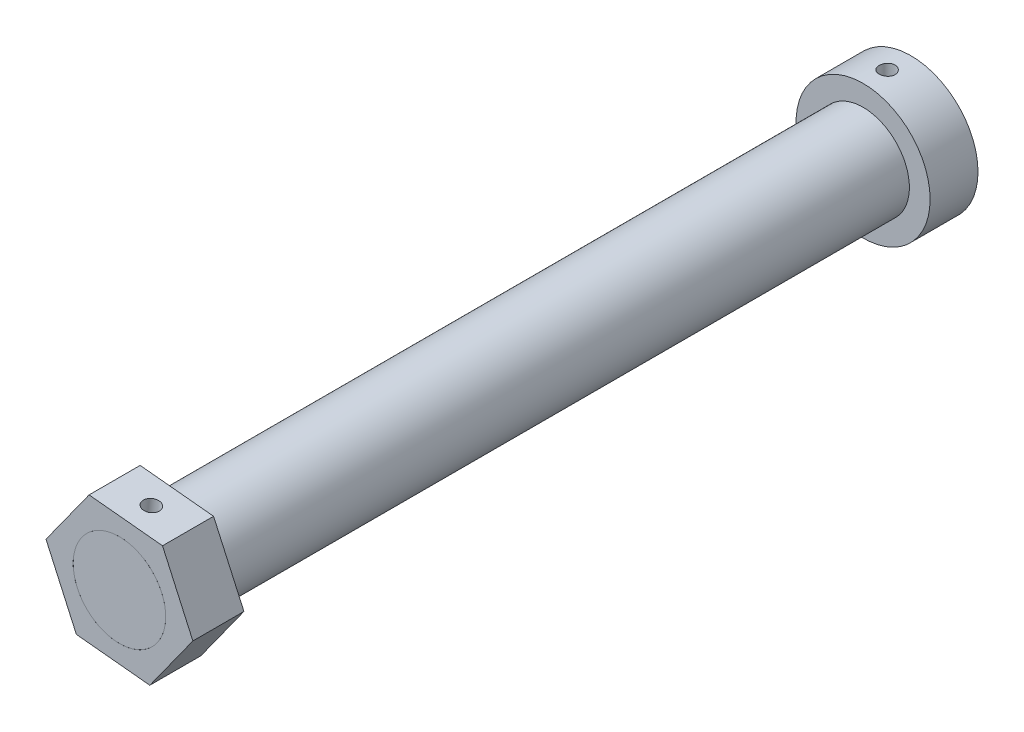
from build123d import *

# Parameters (mm, degrees)
SKETCH1_R           = 21
SKETCH1_R_2         = 14.5
BOSS_EXTRUDE1_DEPTH = 7.5
BOSS_EXTRUDE2_START = 2
SKETCH2_R           = 14.5
BOSS_EXTRUDE2_DEPTH = 250
SKETCH3_R           = 2.5
CUT_EXTRUDE1_DEPTH  = 57.5
SKETCH4_R           = 14.5
BOSS_EXTRUDE3_DEPTH = 16
SKETCH5_R           = 2.5
CUT_EXTRUDE2_DEPTH  = 47


with BuildPart() as part:
    # Sketch1 → Boss-Extrude1 (new body, symmetric)
    with BuildSketch(Plane.XY):
        Circle(SKETCH1_R)
        Circle(SKETCH1_R_2, mode=Mode.SUBTRACT)
    extrude(amount=BOSS_EXTRUDE1_DEPTH, both=True)


with BuildPart() as body_2:
    # Sketch2 → Boss-Extrude2 (new body)
    with BuildSketch(Plane(origin=(0, 0, -7.5), x_dir=(-1, 0, 0), z_dir=(0, 0, -1)).offset(BOSS_EXTRUDE2_START)):
        Circle(SKETCH2_R)
    extrude(amount=-BOSS_EXTRUDE2_DEPTH)


with BuildPart() as cut_extrude1_tool:
    # Sketch3 → Cut-Extrude1 (new body, symmetric)
    with BuildSketch(Plane(origin=(0, 0, 0), x_dir=(1, 0, 0), z_dir=(0, 1, 0))):
        Circle(SKETCH3_R)
    extrude(amount=CUT_EXTRUDE1_DEPTH, both=True)


with BuildPart() as part_1:
    add(part.part)

    # Cut-Extrude1: cut by cut_extrude1_tool
    add(cut_extrude1_tool.part, mode=Mode.SUBTRACT)


with BuildPart() as body_2_1:
    add(body_2.part)

    # Cut-Extrude1: cut by cut_extrude1_tool
    add(cut_extrude1_tool.part, mode=Mode.SUBTRACT)


with BuildPart() as body_3:
    # Sketch4 → Boss-Extrude3 (new body)
    with BuildSketch(Plane.XY.offset(240.5)):
        Polygon((13.497510736, 18.775383524), (-9.51120373, 21.076878947), (-23.008714466, 2.301495423), (-13.497510736, -18.775383524), (9.51120373, -21.076878947), (23.008714466, -2.301495423), align=None)
        Circle(SKETCH4_R, mode=Mode.SUBTRACT)
    extrude(amount=-BOSS_EXTRUDE3_DEPTH)


with BuildPart() as cut_extrude2_tool:
    # Sketch5 → Cut-Extrude2 (new body)
    with BuildSketch(Plane(origin=(1.993153503, 19.926131236, 0), x_dir=(0.995034518, -0.099530436, 0), z_dir=(0.099530436, 0.995034518, 0))):
        with Locations((0, -232.5)):
            Circle(SKETCH5_R)
    extrude(amount=-CUT_EXTRUDE2_DEPTH)


with BuildPart() as body_2_2:
    add(body_2_1.part)

    # Cut-Extrude2: cut by cut_extrude2_tool
    add(cut_extrude2_tool.part, mode=Mode.SUBTRACT)


with BuildPart() as body_3_1:
    add(body_3.part)

    # Cut-Extrude2: cut by cut_extrude2_tool
    add(cut_extrude2_tool.part, mode=Mode.SUBTRACT)


solid = Compound([part_1.part, body_2_2.part, body_3_1.part])
